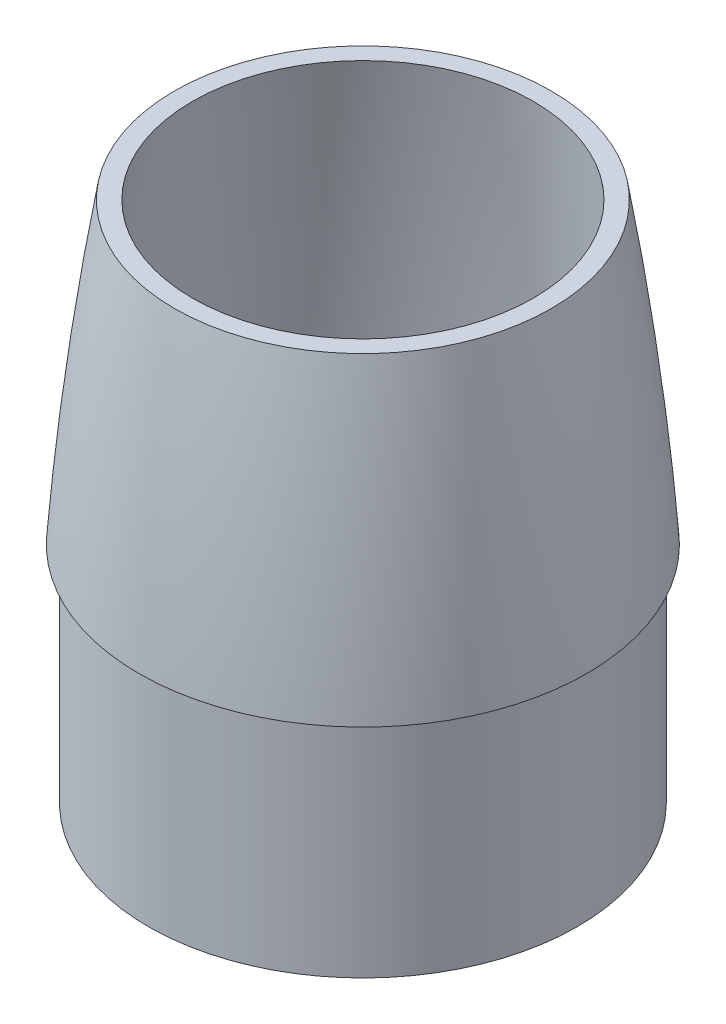
from build123d import *

# Parameters (mm, degrees)
SKETCH7_R           = 317.5
CUT_EXTRUDE2_DEPTH  = 279.4
SKETCH8_R           = 73.025
SKETCH8_R_2         = 69.85
BOSS_EXTRUDE1_DEPTH = 76.2


with BuildPart() as part:
    # Sketch2 → Revolve1 (revolve)
    with BuildSketch(Plane.XY):
        with BuildLine():
            Line((-76.2, 0), (-69.85, 0))
            ThreePointArc((-69.85, 0), (-46.178344337, 164.977710697), (0, 325.12))
            Line((0, 325.12), (0, 330.2))
            ThreePointArc((0, 330.2), (-50.970594074, 168.070137094), (-76.2, 0))
        make_face()
    revolve(axis=Axis((0, 330.2, 0), (0, -1, 0)))

    # Sketch7 → Cut-Extrude2 (cut)
    with BuildSketch(Plane(origin=(0, 381, 0), x_dir=(1, 0, 0), z_dir=(0, 1, 0))):
        Circle(SKETCH7_R)
    extrude(amount=-CUT_EXTRUDE2_DEPTH, mode=Mode.SUBTRACT)

    # Sketch8 → Boss-Extrude1 (add)
    with BuildSketch(Plane.XZ):
        Circle(SKETCH8_R)
        Circle(SKETCH8_R_2, mode=Mode.SUBTRACT)
    extrude(amount=BOSS_EXTRUDE1_DEPTH)


solid = part.part
